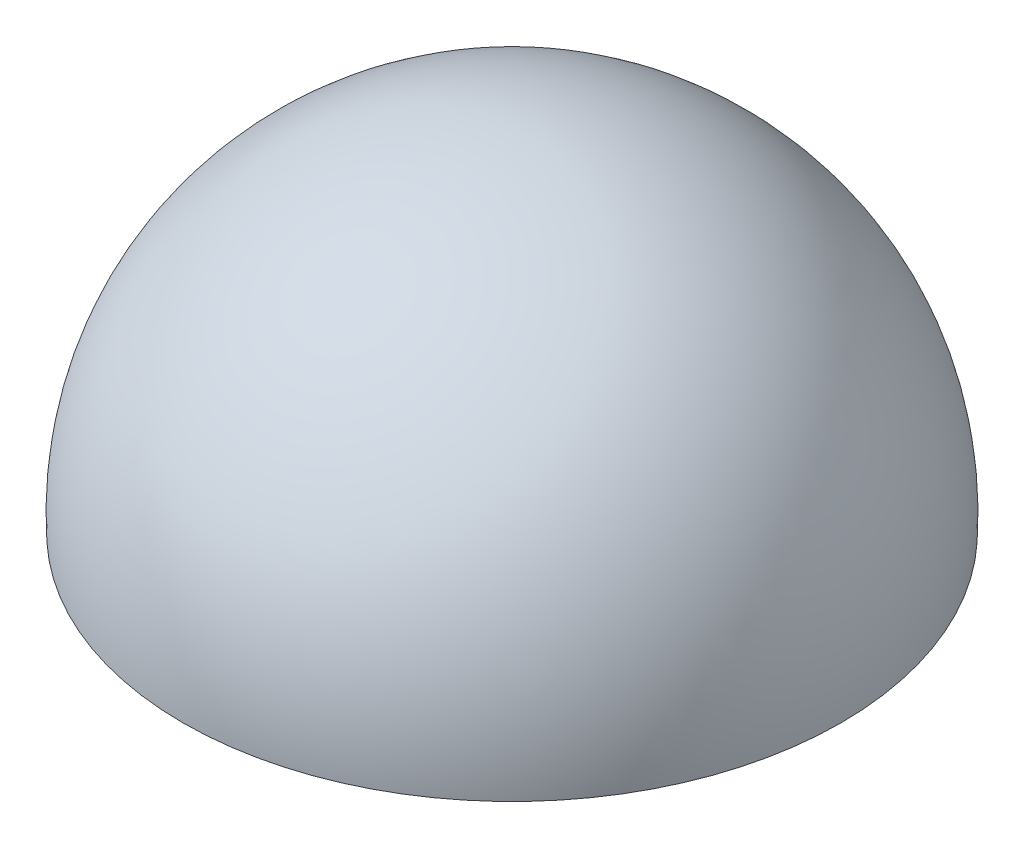
from build123d import *


with BuildPart() as part:
    # Esboço1 → Revolução2 (revolve)
    with BuildSketch(Plane.XY):
        with BuildLine():
            Line((0, -13.07175586), (0, 15.92824414))
            ThreePointArc((0, 15.92824414), (-19.981522347, 7.338412793), (-27.496271405, -13.07175586))
            Line((-27.496271405, -13.07175586), (0, -13.07175586))
        make_face()
    revolve(axis=Axis((0, -13.07175586, 0), (0, 1, 0)))

    # Esboço2 → Corte-Revolução1 (revolve, cut)
    with BuildSketch(Plane.XY):
        with BuildLine():
            Line((0, -12.07175586), (0, 14.919087154))
            ThreePointArc((0, 14.919087154), (-18.912665112, 6.983352145), (-26.5, -12.07175586))
            Line((-26.5, -12.07175586), (0, -12.07175586))
        make_face()
    revolve(axis=Axis((0, -12.07175586, 0), (0, 1, 0)), mode=Mode.SUBTRACT)


solid = part.part
